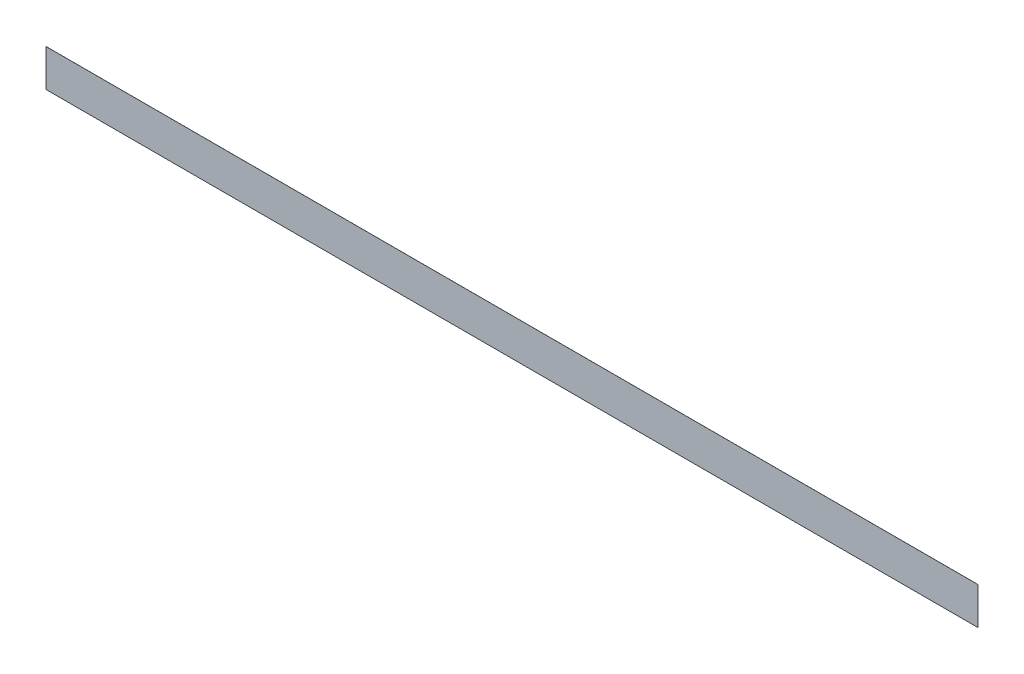
from build123d import *

# Parameters (mm, degrees)
SKETCH1_W           = 250000
SKETCH1_H           = 10000
BOSS_EXTRUDE1_DEPTH = 10


with BuildPart() as part:
    # Sketch1 → Boss-Extrude1 (new body)
    with BuildSketch(Plane.XY):
        Rectangle(SKETCH1_W, SKETCH1_H)
    extrude(amount=BOSS_EXTRUDE1_DEPTH)


solid = part.part
